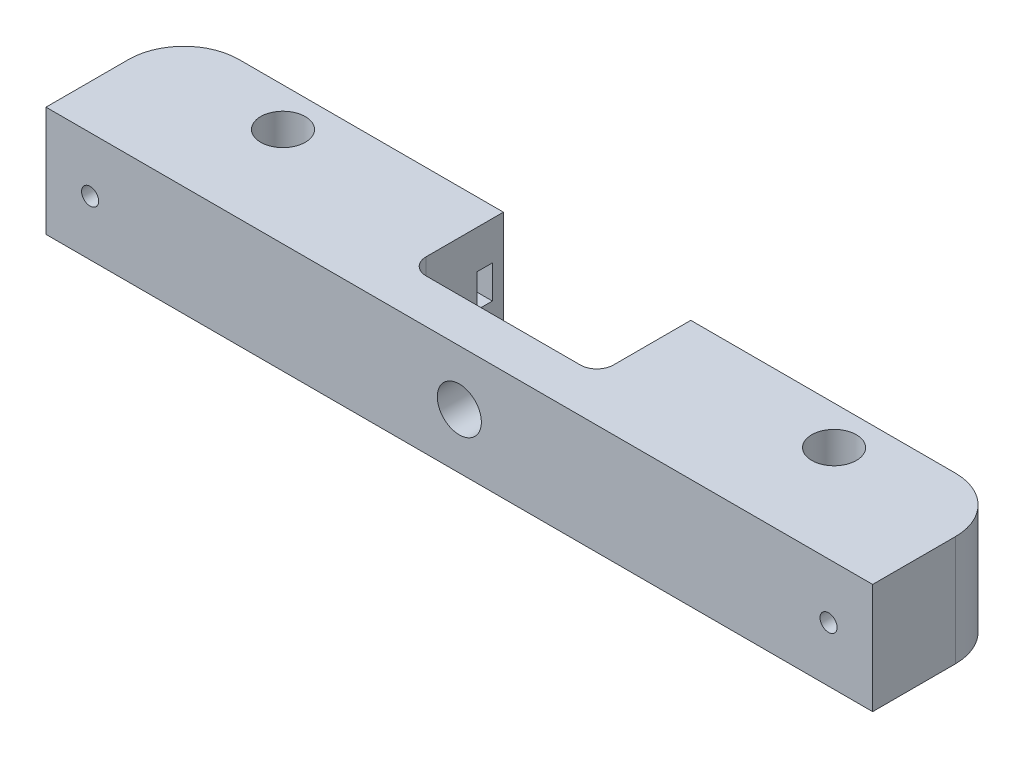
from build123d import *

# Parameters (mm, degrees)
SKETCH1_W           = 150
SKETCH1_H           = 25
SKETCH1_R           = 4.05
BOSS_EXTRUDE1_DEPTH = 20
FILLET1_R           = 10
SKETCH3_R           = 1.55
CUT_EXTRUDE1_DEPTH  = 26
SKETCH3_3_R         = 3.5
SKETCH3_3_R_2       = 1.55
CUT_EXTRUDE2_DEPTH  = 3
SKETCH4_W           = 34
SKETCH4_H           = 34.075617562
CUT_EXTRUDE3_DEPTH  = 21.0000001
SKETCH5_R           = 4
CUT_EXTRUDE4_DEPTH  = 10
FILLET4_R           = 3
SKETCH6_R           = 1.55
CUT_EXTRUDE5_DEPTH  = 10
SKETCH7_W           = 2.8
SKETCH7_H           = 6
CUT_EXTRUDE6_DEPTH  = 10


with BuildPart() as part:
    # Sketch1 → Boss-Extrude1 (new body)
    with BuildSketch(Plane(origin=(0, 0, 0), x_dir=(1, 0, 0), z_dir=(0, 1, 0))):
        Rectangle(SKETCH1_W, SKETCH1_H)
        with Locations(Location((-50, 5.5, 0), (0, 0, 270))):  # turned: the seam where the file's is
            Circle(SKETCH1_R, mode=Mode.SUBTRACT)
        with Locations(Location((50, 5.5, 0), (0, 0, 270))):  # turned: the seam where the file's is
            Circle(SKETCH1_R, mode=Mode.SUBTRACT)
    extrude(amount=BOSS_EXTRUDE1_DEPTH)

    # Fillet1
    fillet1_edges = [part.edges().sort_by_distance(p)[0] for p in [
        (-75, 10, -12.5),
        (75, 10, -12.5),
    ]]
    fillet(fillet1_edges, radius=FILLET1_R)

    # Sketch3 → Cut-Extrude1 (cut, through all)
    with BuildSketch(Plane(origin=(0, 0, -12.5), x_dir=(-1, 0, 0), z_dir=(0, 0, -1))):
        with Locations((-67, 10)):
            Circle(SKETCH3_R)
        with Locations((67, 10)):
            Circle(SKETCH3_R)
    extrude(amount=-CUT_EXTRUDE1_DEPTH, mode=Mode.SUBTRACT)

    # Sketch3_3 → Cut-Extrude2 (cut)
    with BuildSketch(Plane(origin=(0, 0, -12.5), x_dir=(-1, 0, 0), z_dir=(0, 0, -1))):
        with Locations((-67, 10)):
            Circle(SKETCH3_3_R)
        with Locations((-67, 10)):
            Circle(SKETCH3_3_R_2, mode=Mode.SUBTRACT)
        with Locations((67, 10)):
            Circle(SKETCH3_3_R)
        with Locations((67, 10)):
            Circle(SKETCH3_3_R_2, mode=Mode.SUBTRACT)
    extrude(amount=-CUT_EXTRUDE2_DEPTH, mode=Mode.SUBTRACT)

    # Sketch4 → Cut-Extrude3 (cut, through all)
    with BuildSketch(Plane(origin=(0, 20, 0), x_dir=(1, 0, 0), z_dir=(0, 1, 0))):
        with Locations((0, 12.5)):
            Rectangle(SKETCH4_W, SKETCH4_H)
    extrude(amount=-CUT_EXTRUDE3_DEPTH, mode=Mode.SUBTRACT)

    # Sketch5 → Cut-Extrude4 (cut)
    with BuildSketch(Plane(origin=(0, 0, 4.537808781), x_dir=(-1, 0, 0), z_dir=(0, 0, -1))):
        with Locations((0, 10)):
            Circle(SKETCH5_R)
    extrude(amount=-CUT_EXTRUDE4_DEPTH, mode=Mode.SUBTRACT)

    # Fillet4
    fillet4_edges = [part.edges().sort_by_distance(p)[0] for p in [
        (-17, 10, 4.537808781),
        (17, 10, 4.537808781),
    ]]
    fillet(fillet4_edges, radius=FILLET4_R)

    # Sketch6 → Cut-Extrude5 (cut)
    with BuildSketch(Plane(origin=(0, 0, -12.5), x_dir=(-1, 0, 0), z_dir=(0, 0, -1))):
        with Locations((-23.5, 10)):
            Circle(SKETCH6_R)
        with Locations((23.5, 10)):
            Circle(SKETCH6_R)
    extrude(amount=-CUT_EXTRUDE5_DEPTH, mode=Mode.SUBTRACT)

    # Sketch7 → Cut-Extrude6 (cut)
    with BuildSketch(Plane.ZY.offset(-17)):
        with Locations((-9.1, 10.0294943)):
            Rectangle(SKETCH7_W, SKETCH7_H)
    cut_extrude6 = extrude(amount=-CUT_EXTRUDE6_DEPTH, mode=Mode.SUBTRACT)

    # Mirror1: Cut-Extrude6 across plane
    add(cut_extrude6.mirror(Plane(origin=(0, 0, 0), x_dir=(0, 0, 1), z_dir=(1, 0, 0))), mode=Mode.SUBTRACT)


solid = part.part
